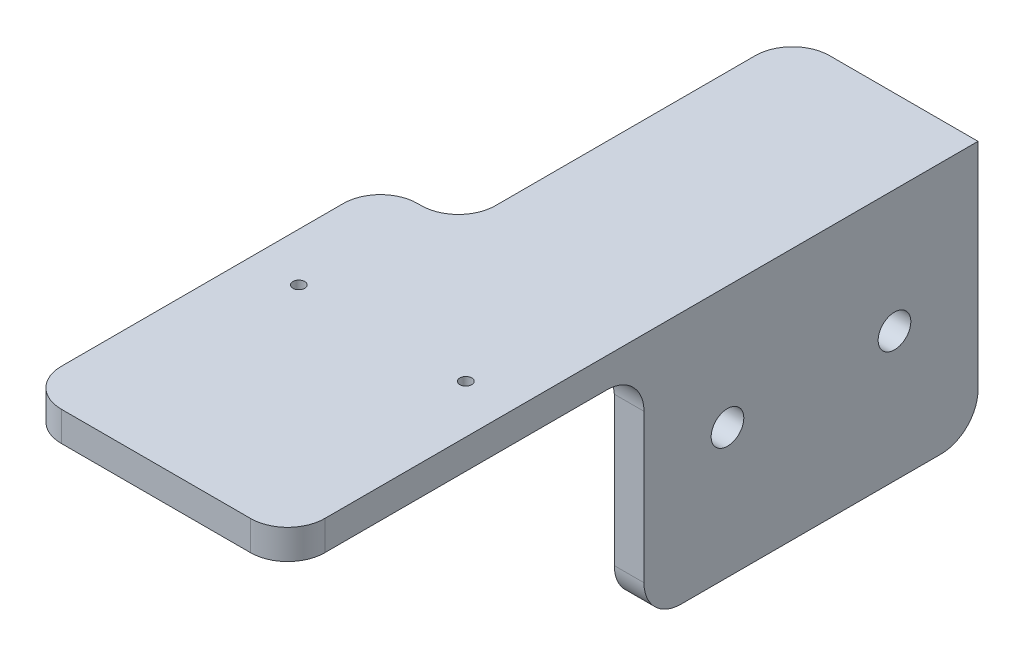
from build123d import *

# Parameters (mm, degrees)
SKETCH1_R           = 1.6
BOSS_EXTRUDE1_DEPTH = 8
SKETCH2_W           = 8
SKETCH2_H           = 90
BOSS_EXTRUDE2_DEPTH = 60
FILLET1_R           = 10
FILLET2_R           = 10
SKETCH3_R           = 4.4
CUT_EXTRUDE1_DEPTH  = 8
FILLET3_R           = 10
FILLET4_R           = 10


with BuildPart() as part:
    # Sketch1 → Boss-Extrude1 (new body)
    with BuildSketch(Plane(origin=(0, 0, 0), x_dir=(1, 0, 0), z_dir=(0, 1, 0))):
        with BuildLine():
            Line((-25.5, 48), (-24.5, 48))
            ThreePointArc((-24.5, 48), (-17.428932188, 50.928932188), (-14.5, 58))
            Line((-14.5, 58), (-14.5, 128))
            ThreePointArc((-14.5, 128), (-11.571067812, 135.071067812), (-4.5, 138))
            Line((-4.5, 138), (35.5, 138))
            Line((35.5, 138), (35.5, 48))
            Line((35.5, 48), (35.5, -38))
            ThreePointArc((35.5, -38), (32.571067812, -45.071067812), (25.5, -48))
            Line((25.5, -48), (-25.5, -48))
            ThreePointArc((-25.5, -48), (-32.571067812, -45.071067812), (-35.5, -38))
            Line((-35.5, -38), (-35.5, 38))
            ThreePointArc((-35.5, 38), (-32.571067812, 45.071067812), (-25.5, 48))
        make_face()
        with Locations((-22.5, 13)):
            Circle(SKETCH1_R, mode=Mode.SUBTRACT)
        with Locations((22.5, 13)):
            Circle(SKETCH1_R, mode=Mode.SUBTRACT)
    extrude(amount=BOSS_EXTRUDE1_DEPTH)

    # Sketch2 → Boss-Extrude2 (add)
    with BuildSketch(Plane.XZ):
        with Locations((31.5, -93)):
            Rectangle(SKETCH2_W, SKETCH2_H)
    extrude(amount=BOSS_EXTRUDE2_DEPTH)

    # Fillet1
    fillet1_edges = [part.edges().sort_by_distance(p)[0] for p in [
        (31.5, -60, -138),
    ]]
    fillet(fillet1_edges, radius=FILLET1_R)

    # Fillet2
    fillet2_edges = [part.edges().sort_by_distance(p)[0] for p in [
        (31.5, -60, -48),
    ]]
    fillet(fillet2_edges, radius=FILLET2_R)

    # Sketch3 → Cut-Extrude1 (cut)
    with BuildSketch(Plane(origin=(35.5, 0, 0), x_dir=(0, 0, -1), z_dir=(1, 0, 0))):
        with Locations((70.5, -25)):
            Circle(SKETCH3_R)
        with Locations((115.5, -25)):
            Circle(SKETCH3_R)
    extrude(amount=-CUT_EXTRUDE1_DEPTH, mode=Mode.SUBTRACT)

    # Fillet3
    fillet3_edges = [part.edges().sort_by_distance(p)[0] for p in [
        (27.5, 0, -93),
    ]]
    fillet(fillet3_edges, radius=FILLET3_R)

    # Fillet4
    fillet4_edges = [part.edges().sort_by_distance(p)[0] for p in [
        (22.5, 0, -48),
    ]]
    fillet(fillet4_edges, radius=FILLET4_R)


solid = part.part
